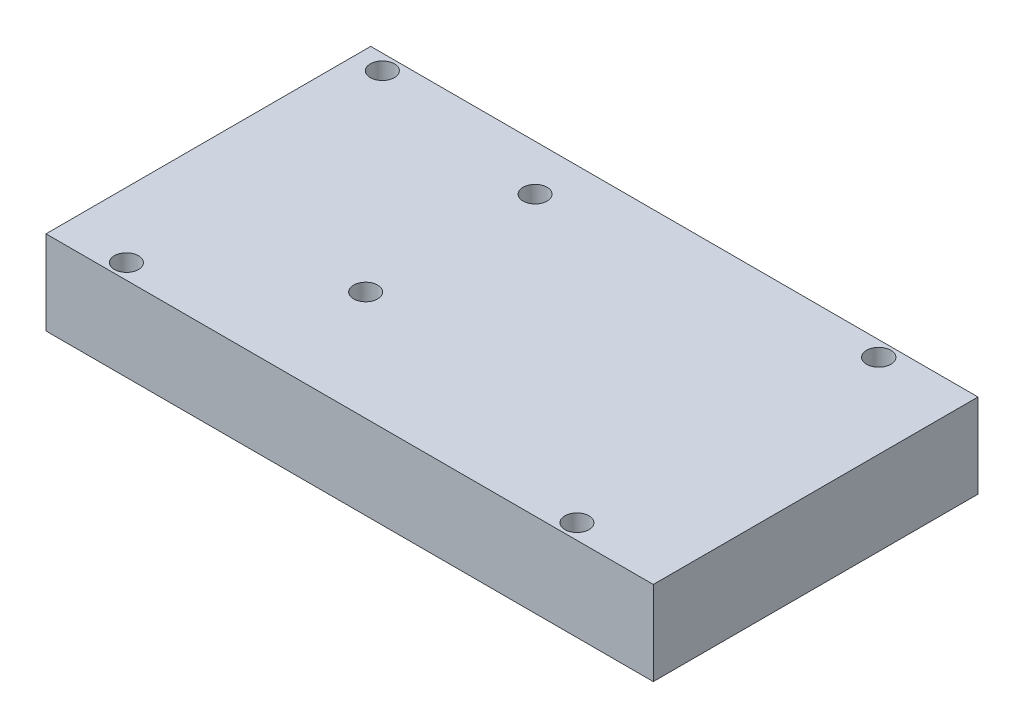
from build123d import *

# Parameters (mm, degrees)
SKETCH1_W           = 101
SKETCH1_H           = 54
BOSS_EXTRUDE1_DEPTH = 14
SKETCH2_R           = 2
SKETCH2_R_2         = 2.023276888
CUT_EXTRUDE1_DEPTH  = 100


with BuildPart() as part:
    # Sketch1 → Boss-Extrude1 (new body)
    with BuildSketch(Plane(origin=(0, 0, 0), x_dir=(1, 0, 0), z_dir=(0, 1, 0))):
        Rectangle(SKETCH1_W, SKETCH1_H)
    extrude(amount=BOSS_EXTRUDE1_DEPTH)

    # Sketch2 → Cut-Extrude1 (cut)
    with BuildSketch(Plane(origin=(0, 14, 0), x_dir=(1, 0, 0), z_dir=(0, 1, 0))):
        with Locations((-46.02, 24.46)):
            Circle(SKETCH2_R)
        with Locations((-39.67, -24.46)):
            Circle(SKETCH2_R)
        with Locations((36.53, 24.46)):
            Circle(SKETCH2_R_2)
        with Locations((35.26, -24.46)):
            Circle(SKETCH2_R)
        with Locations((-15.54, 19.38)):
            Circle(SKETCH2_R)
        with Locations((-15.54, -8.798902871)):
            Circle(SKETCH2_R)
    extrude(amount=-CUT_EXTRUDE1_DEPTH, mode=Mode.SUBTRACT)


solid = part.part
